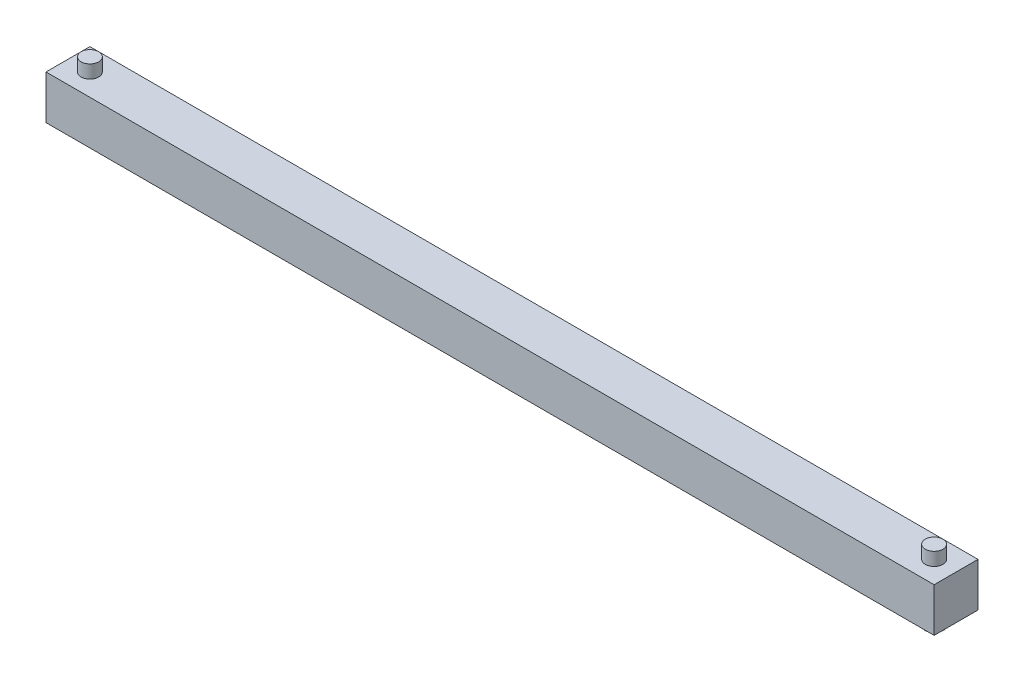
from build123d import *

# Parameters (mm, degrees)
SKETCH_1_W      = 4
SKETCH_1_H      = 8
SKETCH_1_W_2    = 153.851648
EXTRUDE_1_DEPTH = 8
SKETCH_2_R      = 1.6
EXTRUDE_2_DEPTH = 2.4
SKETCH_3_R      = 1.6
SKETCH_3_R_2    = 1.65
EXTRUDE_3_DEPTH = 2.4


with BuildPart() as part:
    # 草图1 → 凸台-拉伸1 (new body)
    with BuildSketch(Plane.XY):
        with Locations((-94.582983627, -9.313586075)):
            Rectangle(SKETCH_1_W, SKETCH_1_H)
        with Locations((-15.657159627, -9.313586075)):
            Rectangle(SKETCH_1_W_2, SKETCH_1_H)
        with Locations((63.268664373, -9.313586075)):
            Rectangle(SKETCH_1_W, SKETCH_1_H)
    extrude(amount=EXTRUDE_1_DEPTH)

    # 草图2 → 凸台-拉伸2 (add)
    with BuildSketch(Plane(origin=(0, -5.313586075, 0), x_dir=(1, 0, 0), z_dir=(0, 1, 0))):
        with Locations((-92.582983627, -4)):
            Circle(SKETCH_2_R)
        with Locations((61.268664373, -4)):
            Circle(SKETCH_2_R)
    extrude(amount=EXTRUDE_2_DEPTH)

    # 草图3 → 凸台-拉伸3 (add)
    with BuildSketch(Plane(origin=(0, -13.313586075, 0), x_dir=(-1, 0, 0), z_dir=(0, -1, 0))):
        with Locations((92.582983627, -4)):
            Circle(SKETCH_3_R)
        with Locations((-61.268664373, -4)):
            Circle(SKETCH_3_R_2)
    extrude(amount=EXTRUDE_3_DEPTH)


solid = part.part
